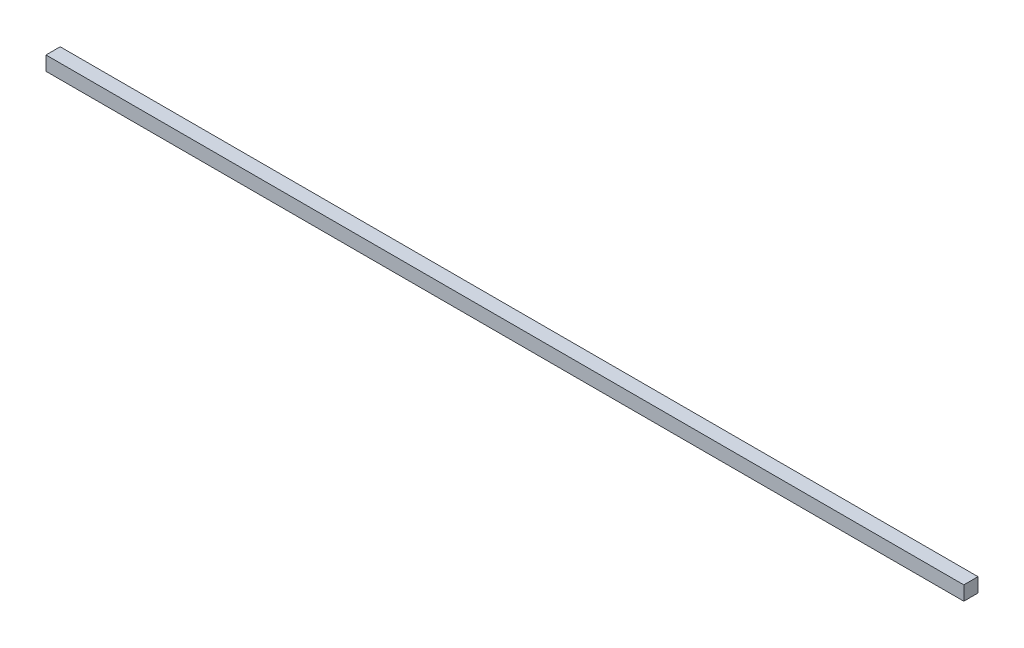
from build123d import *

# Parameters (mm, degrees)
SKETCH1_W           = 4.7625
SKETCH1_H           = 4.7625
BOSS_EXTRUDE1_DEPTH = 307.975


with BuildPart() as part:
    # Sketch1 → Boss-Extrude1 (new body)
    with BuildSketch(Plane(origin=(0, 0, 0), x_dir=(0, 0, -1), z_dir=(1, 0, 0))):
        with Locations((2.38125, 2.38125)):
            Rectangle(SKETCH1_W, SKETCH1_H)
    extrude(amount=-BOSS_EXTRUDE1_DEPTH)


solid = part.part
